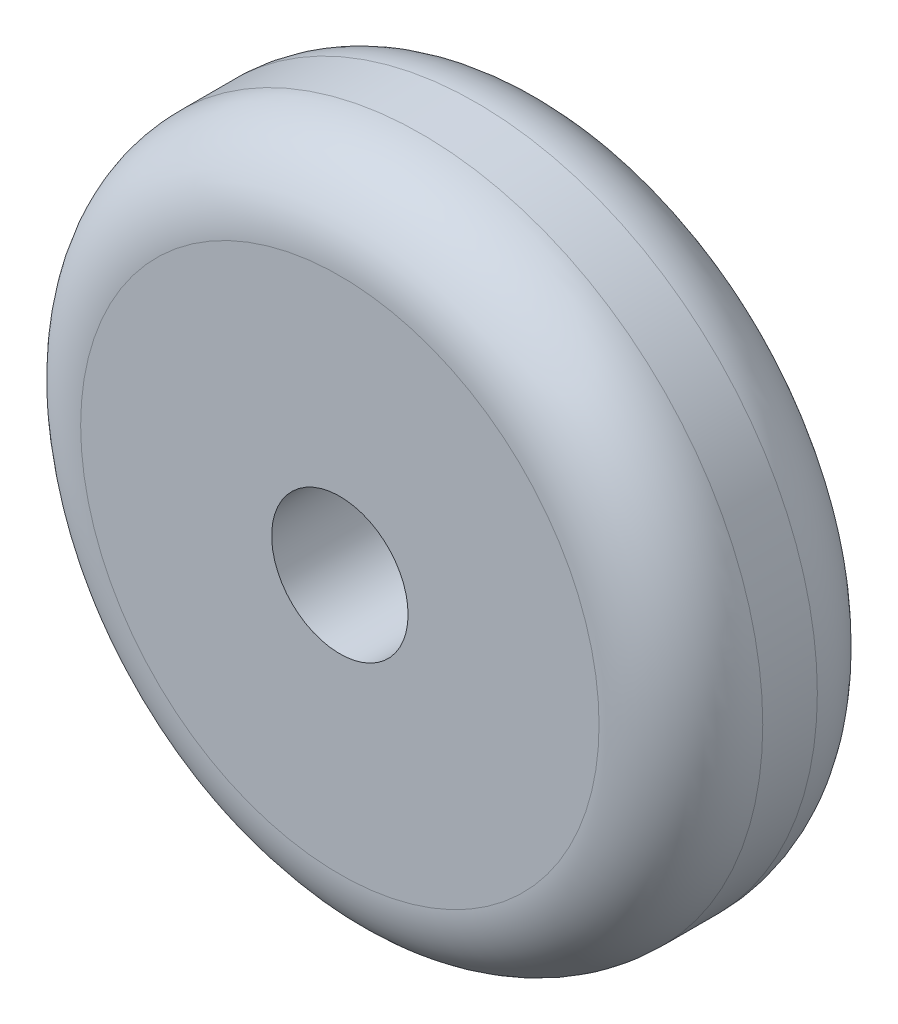
from build123d import *

# Parameters (mm, degrees)
SKETCH1_R           = 12.5
SKETCH1_R_2         = 2.5
BOSS_EXTRUDE1_DEPTH = 4
FILLET1_R           = 3


with BuildPart() as part:
    # Sketch1 → Boss-Extrude1 (new body, symmetric)
    with BuildSketch(Plane.XY):
        Circle(SKETCH1_R)
        Circle(SKETCH1_R_2, mode=Mode.SUBTRACT)
    extrude(amount=BOSS_EXTRUDE1_DEPTH, both=True)

    # Fillet1
    fillet1_edges = [part.edges().sort_by_distance(p)[0] for p in [
        (-12.5, 0, -4),
        (-12.5, 0, 4),
    ]]
    fillet(fillet1_edges, radius=FILLET1_R)


solid = part.part
